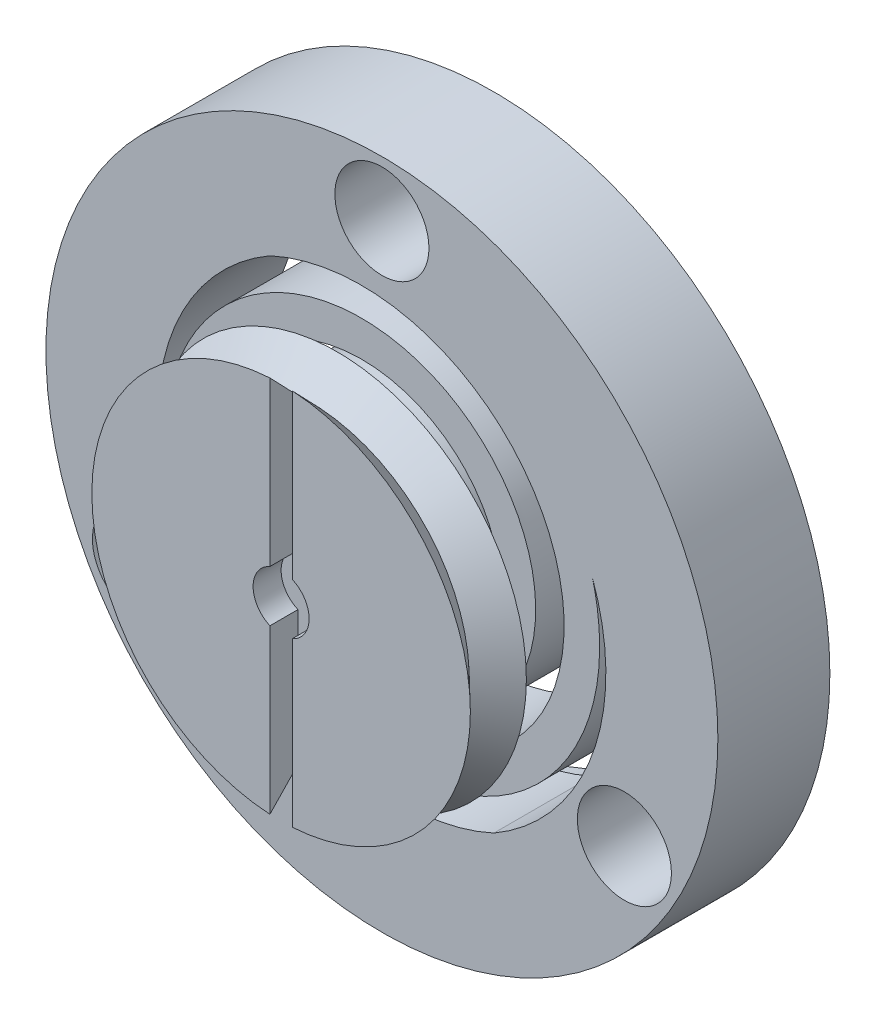
from build123d import *

# Parameters (mm, degrees)
SKETCH_1_R          = 15
SKETCH_1_R_2        = 10
SKETCH_1_R_3        = 1.1
EXTRUDE_1_DEPTH     = 1.4
SKETCH_2_R          = 15
SKETCH_2_R_2        = 10
SKETCH_2_R_3        = 2.1
EXTRUDE_2_DEPTH     = 3.6
EXTRUDE_3_DEPTH     = 4.4
SKETCH_9_R          = 3.25
CUT_EXTRUDE_1_DEPTH = 2.5
SKETCH_10_R         = 4
EXTRUDE_4_DEPTH     = 2
SKETCH_11_R         = 8.45
EXTRUDE_5_DEPTH     = 2.5
CUT_EXTRUDE_2_DEPTH = 1.25


with BuildPart() as part:
    # Sketch 1 → Extrude 1 (new body)
    with BuildSketch(Plane.XY):
        Circle(SKETCH_1_R)
        Circle(SKETCH_1_R_2, mode=Mode.SUBTRACT)
        with Locations((0, 12.5)):
            Circle(SKETCH_1_R_3, mode=Mode.SUBTRACT)
        with Locations((10.825317547, -6.25)):
            Circle(SKETCH_1_R_3, mode=Mode.SUBTRACT)
        with Locations((-10.825317547, -6.25)):
            Circle(SKETCH_1_R_3, mode=Mode.SUBTRACT)
    extrude(amount=EXTRUDE_1_DEPTH)

    # Sketch 2 → Extrude 2 (add)
    with BuildSketch(Plane.XY.offset(1.4)):
        Circle(SKETCH_2_R)
        Circle(SKETCH_2_R_2, mode=Mode.SUBTRACT)
        with Locations((0, 12.5)):
            Circle(SKETCH_2_R_3, mode=Mode.SUBTRACT)
        with Locations((10.825317547, -6.25)):
            Circle(SKETCH_2_R_3, mode=Mode.SUBTRACT)
        with Locations((-10.825317547, -6.25)):
            Circle(SKETCH_2_R_3, mode=Mode.SUBTRACT)
    extrude(amount=EXTRUDE_2_DEPTH)

    # Sketch 8 → Extrude 3 (add)
    with BuildSketch(Plane.XY.offset(5)):
        with BuildLine():
            ThreePointArc((-2.125, 3.680607966), (-3.993693638, 1.453585609), (-3.993693638, -1.453585609))
            add(Edge.make_bspline(
                [(-9.396926208, -3.420201433), (-9.732062183, -2.149175506), (-9.806172611, -0.835010365), (-9.456725912, 1.676046677), (-9.033681598, 2.871966971), (-7.789656699, 4.972884513), (-6.969506065, 5.877213907), (-5.085556702, 7.278578571), (-4.022753032, 7.775339442), (-1.834341922, 8.316896689), (-0.709724019, 8.361833006), (1.425354593, 8.02880188), (2.434991624, 7.65134079), (4.194832357, 6.566362619), (4.944502403, 5.859612911), (6.091617732, 4.253128009), (6.488888652, 3.354278704), (6.901731194, 1.519508339), (6.917493401, 0.584437672), (6.600877847, -1.174662508), (6.268999982, -1.998016278), (5.34306854, -3.416780201), (4.749719757, -4.011790899), (3.420699316, -4.904656893), (2.685804375, -5.202437862), (1.204674755, -5.486565699), (0.459151326, -5.473153796), (-0.923970423, -5.172953815), (-1.561040931, -4.886659174), (-2.638728045, -4.11977446), (-3.079079395, -3.639826603), (-3.717696054, -2.588270623), (-3.915987072, -2.017330047), (-3.993693638, -1.453585609)],
                knots=[0, 0, 0, 0, 0.0625, 0.0625, 0.125, 0.125, 0.1875, 0.1875, 0.25, 0.25, 0.3125, 0.3125, 0.375, 0.375, 0.4375, 0.4375, 0.5, 0.5, 0.5625, 0.5625, 0.625, 0.625, 0.6875, 0.6875, 0.75, 0.75, 0.8125, 0.8125, 0.875, 0.875, 0.9375, 0.9375, 1, 1, 1, 1], degree=3))
            ThreePointArc((-9.396926208, -3.420201433), (-3.420201433, -9.396926208), (5, -8.660254038))
            add(Edge.make_bspline(
                [(5, -8.660254038), (3.806479564, -9.211009881), (2.525148685, -9.512196786), (-0.008440541, -9.604099447), (-1.259652992, -9.395151506), (-3.544675532, -8.534846644), (-4.577683795, -7.884191092), (-6.284902954, -6.272207574), (-6.958670832, -5.311811899), (-7.872014208, -3.250688101), (-8.111555691, -2.150958779), (-8.154336566, 0.009513438), (-7.957931589, 1.069357245), (-7.195029811, 2.990866525), (-6.629196056, 3.851873198), (-5.246311756, 5.260524443), (-4.430103363, 5.807843469), (-2.694896637, 6.533018535), (-1.776768874, 6.710914596), (0.010586336, 6.704573685), (0.879061498, 6.520711671), (2.437057517, 5.855212978), (3.126062601, 5.37420102), (4.236145931, 4.220415939), (4.657016106, 3.548394826), (5.194022862, 2.139105174), (5.310273501, 1.402578969), (5.254810803, -0.011659233), (5.083491754, -0.688765751), (4.515396145, -1.883248509), (4.119205984, -2.400252004), (3.194520122, -3.21176742), (2.666686289, -3.506188743), (2.125, -3.680607966)],
                knots=[0, 0, 0, 0, 0.0625, 0.0625, 0.125, 0.125, 0.1875, 0.1875, 0.25, 0.25, 0.3125, 0.3125, 0.375, 0.375, 0.4375, 0.4375, 0.5, 0.5, 0.5625, 0.5625, 0.625, 0.625, 0.6875, 0.6875, 0.75, 0.75, 0.8125, 0.8125, 0.875, 0.875, 0.9375, 0.9375, 1, 1, 1, 1], degree=3))
            ThreePointArc((2.125, -3.680607966), (3.993693638, -1.453585609), (3.993693638, 1.453585609))
            add(Edge.make_bspline(
                [(9.396926208, 3.420201433), (9.732062183, 2.149175506), (9.806172611, 0.835010365), (9.456725912, -1.676046677), (9.033681598, -2.871966971), (7.789656699, -4.972884513), (6.969506065, -5.877213907), (5.085556702, -7.278578571), (4.022753032, -7.775339442), (1.834341922, -8.316896689), (0.709724019, -8.361833006), (-1.425354593, -8.02880188), (-2.434991624, -7.65134079), (-4.194832357, -6.566362619), (-4.944502403, -5.859612911), (-6.091617732, -4.253128009), (-6.488888652, -3.354278704), (-6.901731194, -1.519508339), (-6.917493401, -0.584437672), (-6.600877847, 1.174662508), (-6.268999982, 1.998016278), (-5.34306854, 3.416780201), (-4.749719757, 4.011790899), (-3.420699316, 4.904656893), (-2.685804375, 5.202437862), (-1.204674755, 5.486565699), (-0.459151326, 5.473153796), (0.923970423, 5.172953815), (1.561040931, 4.886659174), (2.638728045, 4.11977446), (3.079079395, 3.639826603), (3.717696054, 2.588270623), (3.915987072, 2.017330047), (3.993693638, 1.453585609)],
                knots=[0, 0, 0, 0, 0.0625, 0.0625, 0.125, 0.125, 0.1875, 0.1875, 0.25, 0.25, 0.3125, 0.3125, 0.375, 0.375, 0.4375, 0.4375, 0.5, 0.5, 0.5625, 0.5625, 0.625, 0.625, 0.6875, 0.6875, 0.75, 0.75, 0.8125, 0.8125, 0.875, 0.875, 0.9375, 0.9375, 1, 1, 1, 1], degree=3))
            ThreePointArc((9.396926208, 3.420201433), (3.420201433, 9.396926208), (-5, 8.660254038))
            add(Edge.make_bspline(
                [(-5, 8.660254038), (-3.806479564, 9.211009881), (-2.525148685, 9.512196786), (0.008440541, 9.604099447), (1.259652992, 9.395151506), (3.544675532, 8.534846644), (4.577683795, 7.884191092), (6.284902954, 6.272207574), (6.958670832, 5.311811899), (7.872014208, 3.250688101), (8.111555691, 2.150958779), (8.154336566, -0.009513438), (7.957931589, -1.069357245), (7.195029811, -2.990866525), (6.629196056, -3.851873198), (5.246311756, -5.260524443), (4.430103363, -5.807843469), (2.694896637, -6.533018535), (1.776768874, -6.710914596), (-0.010586336, -6.704573685), (-0.879061498, -6.520711671), (-2.437057517, -5.855212978), (-3.126062601, -5.37420102), (-4.236145931, -4.220415939), (-4.657016106, -3.548394826), (-5.194022862, -2.139105174), (-5.310273501, -1.402578969), (-5.254810803, 0.011659233), (-5.083491754, 0.688765751), (-4.515396145, 1.883248509), (-4.119205984, 2.400252004), (-3.194520122, 3.21176742), (-2.666686289, 3.506188743), (-2.125, 3.680607966)],
                knots=[0, 0, 0, 0, 0.0625, 0.0625, 0.125, 0.125, 0.1875, 0.1875, 0.25, 0.25, 0.3125, 0.3125, 0.375, 0.375, 0.4375, 0.4375, 0.5, 0.5, 0.5625, 0.5625, 0.625, 0.625, 0.6875, 0.6875, 0.75, 0.75, 0.8125, 0.8125, 0.875, 0.875, 0.9375, 0.9375, 1, 1, 1, 1], degree=3))
        make_face()
    extrude(amount=-EXTRUDE_3_DEPTH)

    # Sketch 9 → Cut-Extrude 1 (cut)
    with BuildSketch(Plane(origin=(0, 0, 0.6), x_dir=(-1, 0, 0), z_dir=(0, 0, -1))):
        Circle(SKETCH_9_R)
    extrude(amount=-CUT_EXTRUDE_1_DEPTH, mode=Mode.SUBTRACT)

    # Sketch 10 → Extrude 4 (add)
    with BuildSketch(Plane.XY.offset(5)):
        Circle(SKETCH_10_R)
    extrude(amount=EXTRUDE_4_DEPTH)

    # Sketch 11 → Extrude 5 (add)
    with BuildSketch(Plane.XY.offset(7)):
        Circle(SKETCH_11_R)
    extrude(amount=EXTRUDE_5_DEPTH)

    # Sketch 12 → Cut-Revolve 1 (revolve, cut)
    with BuildSketch(Plane(origin=(0, 0, 0), x_dir=(0, 0, -1), z_dir=(1, 0, 0))):
        Polygon((-9.5, 8.45), (-7, 8.45), (-8.25, 7.15), align=None)
    revolve(axis=Axis((0, 0, 0), (0, 0, 1)), mode=Mode.SUBTRACT)

    # Sketch 13 → Cut-Extrude 2 (cut)
    with BuildSketch(Plane.XY.offset(9.5)):
        with BuildLine():
            Line((-0.5, 1.145643924), (-0.5, 9))
            Line((-0.5, 9), (0.5, 9))
            Line((0.5, 9), (0.5, 1.145643924))
            ThreePointArc((0.5, 1.145643924), (1.25, 0), (0.5, -1.145643924))
            Line((0.5, -1.145643924), (0.5, -9))
            Line((0.5, -9), (-0.5, -9))
            Line((-0.5, -9), (-0.5, -1.145643924))
            ThreePointArc((-0.5, -1.145643924), (-1.25, 0), (-0.5, 1.145643924))
        make_face()
    extrude(amount=-CUT_EXTRUDE_2_DEPTH, mode=Mode.SUBTRACT)


solid = part.part
